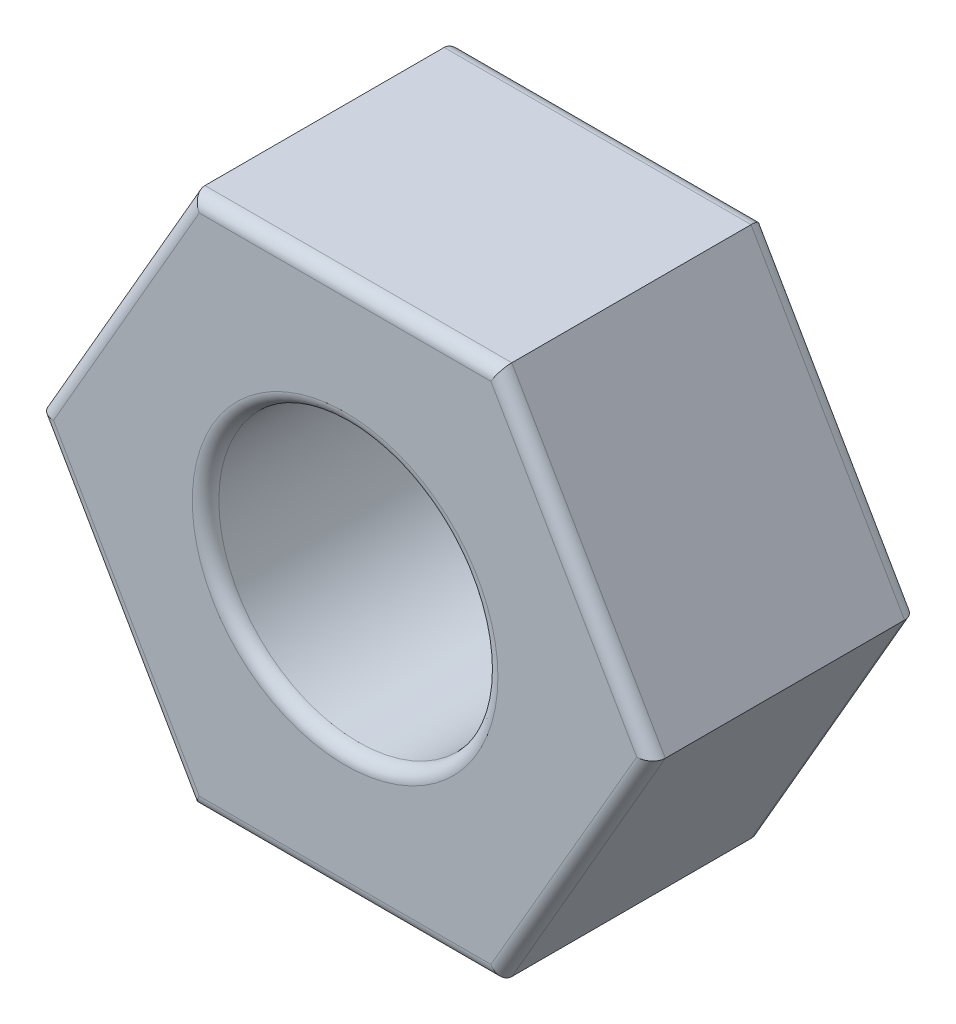
from build123d import *

# Parameters (mm, degrees)
SKETCH1_R           = 2.1
BOSS_EXTRUDE1_DEPTH = 4
FILLET1_R           = 0.2


with BuildPart() as part:
    # Sketch1 → Boss-Extrude1 (new body)
    with BuildSketch(Plane.XY):
        Polygon((4.618802154, 0), (2.309401077, 4), (-2.309401077, 4), (-4.618802154, 0), (-2.309401077, -4), (2.309401077, -4), align=None)
        Circle(SKETCH1_R, mode=Mode.SUBTRACT)
    extrude(amount=BOSS_EXTRUDE1_DEPTH)

    # Fillet1
    fillet1_edges = [part.edges().sort_by_distance(p)[0] for p in [
        (0, 4, 4),
        (-3.464101615, 2, 4),
        (-3.464101615, -2, 4),
        (-2.1, 0, 0),
        (-2.1, 0, 4),
        (0, -4, 4),
        (3.464101615, -2, 4),
        (0, -4, 0),
        (-3.464101615, -2, 0),
        (-3.464101615, 2, 0),
        (3.464101615, 2, 4),
        (0, 4, 0),
        (3.464101615, 2, 0),
        (3.464101615, -2, 0),
    ]]
    fillet(fillet1_edges, radius=FILLET1_R)


solid = part.part
